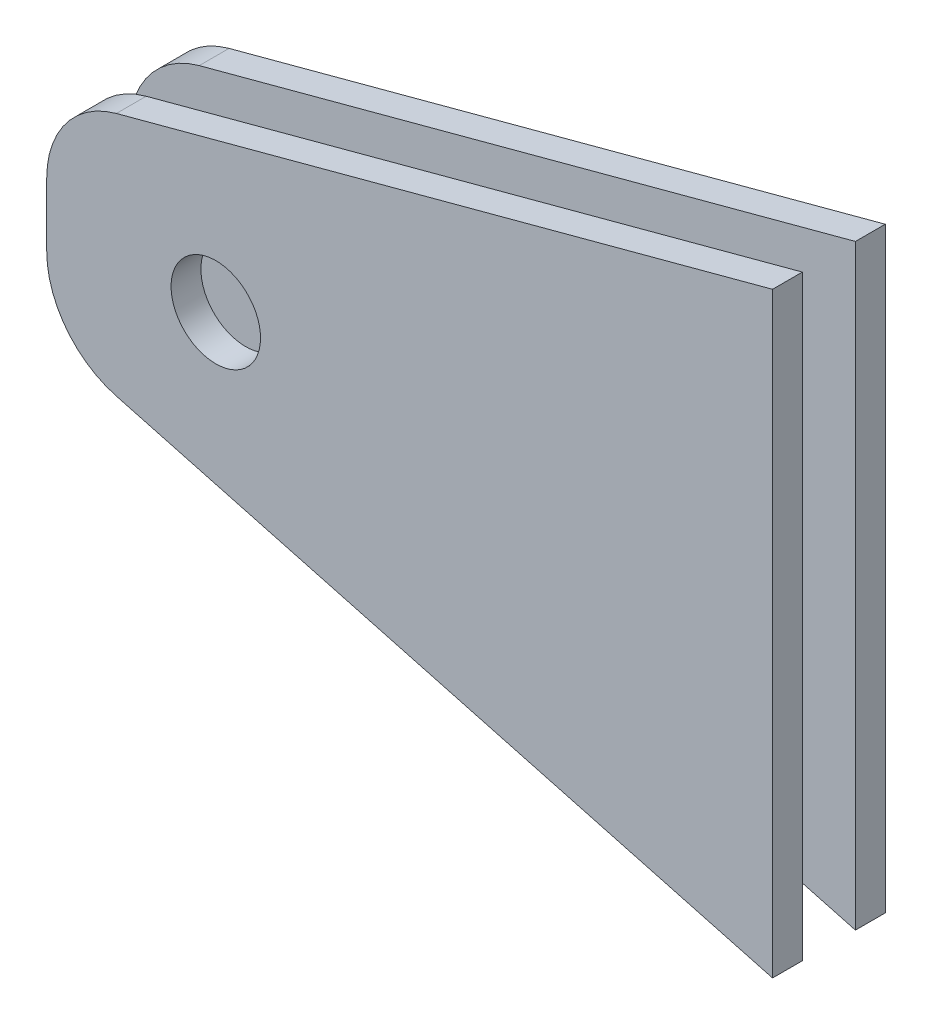
from build123d import *

# Parameters (mm, degrees)
SALIENTE_EXTRUIR1_DEPTH = 12
CROQUIS2_R              = 4.7625
CORTAR_EXTRUIR1_DEPTH   = 12
REDONDEO1_R             = 10
CROQUIS3_W              = 5.65
CROQUIS3_H              = 93.399024574
CORTAR_EXTRUIR2_DEPTH   = 100


with BuildPart() as part:
    # Croquis1 → Saliente-Extruir1 (new body)
    with BuildSketch(Plane.XY):
        Polygon((0, 0), (0, 63.5), (-77.274066103, 42.794476392), (-77.274066103, 20.705523608), align=None)
    extrude(amount=SALIENTE_EXTRUIR1_DEPTH)

    # Croquis2 → Cortar-Extruir1 (cut)
    with BuildSketch(Plane.XY.offset(12)):
        with Locations((-59.274066103, 31.75)):
            Circle(CROQUIS2_R)
    extrude(amount=-CORTAR_EXTRUIR1_DEPTH, mode=Mode.SUBTRACT)

    # Redondeo1
    redondeo1_edges = [part.edges().sort_by_distance(p)[0] for p in [
        (-77.274066103, 20.705523608, 6),
        (-77.274066103, 42.794476392, 6),
    ]]
    fillet(redondeo1_edges, radius=REDONDEO1_R)

    # Croquis3 → Cortar-Extruir2 (cut)
    with BuildSketch(Plane.ZY.offset(77.274066103)):
        with Locations((6, 31.75)):
            Rectangle(CROQUIS3_W, CROQUIS3_H)
    extrude(amount=-CORTAR_EXTRUIR2_DEPTH, mode=Mode.SUBTRACT)


solid = part.part
